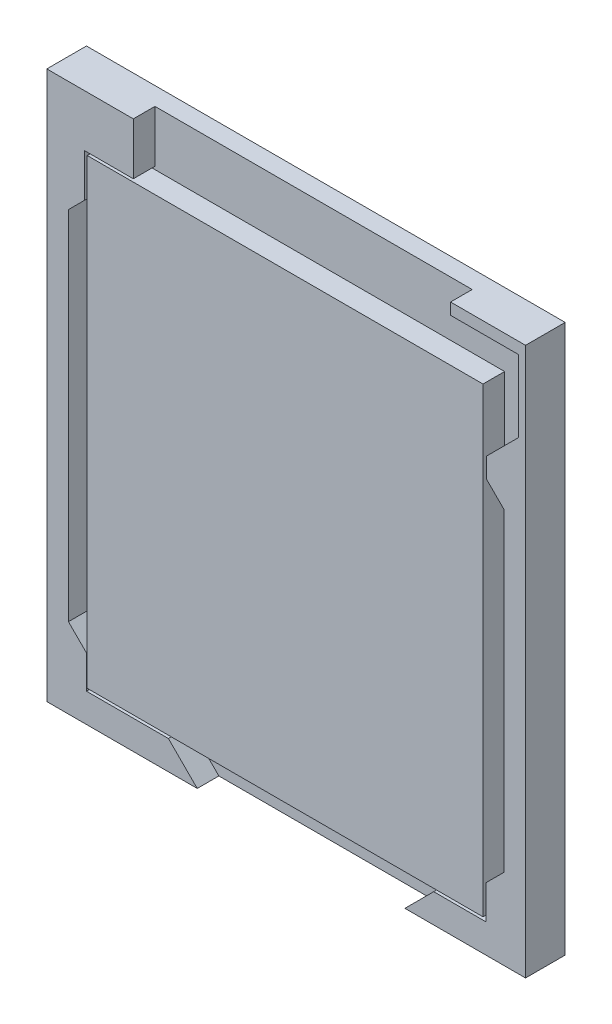
from build123d import *

# Parameters (mm, degrees)
SKETCH1_W           = 33.2
SKETCH1_H           = 38
BOSS_EXTRUDE1_DEPTH = 2.75
CUT_EXTRUDE1_DEPTH  = 1.5
SKETCH3_W           = 27.45
SKETCH3_H           = 32
BOSS_EXTRUDE2_DEPTH = 1.5


with BuildPart() as part:
    # Sketch1 → Boss-Extrude1 (new body)
    with BuildSketch(Plane.XY):
        Rectangle(SKETCH1_W, SKETCH1_H)
    extrude(amount=BOSS_EXTRUDE1_DEPTH)

    # Sketch2 → Cut-Extrude1 (cut)
    with BuildSketch(Plane.XY.offset(2.75)):
        Polygon((-6.16774695, -19), (8.23225305, -19), (10.23225305, -17), (13.85, -17), (13.85, -14.655424434), (15.1, -13.405424434), (15.1, 8.4), (13.9, 9.6), (13.9, 11), (16.1, 13.2), (16.1, 18.2), (11.4, 18.2), (11.4, 19), (-10.6, 19), (-10.6, 15.4), (-14, 15.4), (-14, 12.4), (-15.1, 11.3), (-15.1, -13.45), (-13.85, -14.7), (-13.85, -17), (-8.16774695, -17), align=None)
    extrude(amount=-CUT_EXTRUDE1_DEPTH, mode=Mode.SUBTRACT)

    # Sketch3 → Boss-Extrude2 (add)
    with BuildSketch(Plane.XY.offset(1.25)):
        with Locations((-0.075, -0.8)):
            Rectangle(SKETCH3_W, SKETCH3_H)
    extrude(amount=BOSS_EXTRUDE2_DEPTH)


solid = part.part
